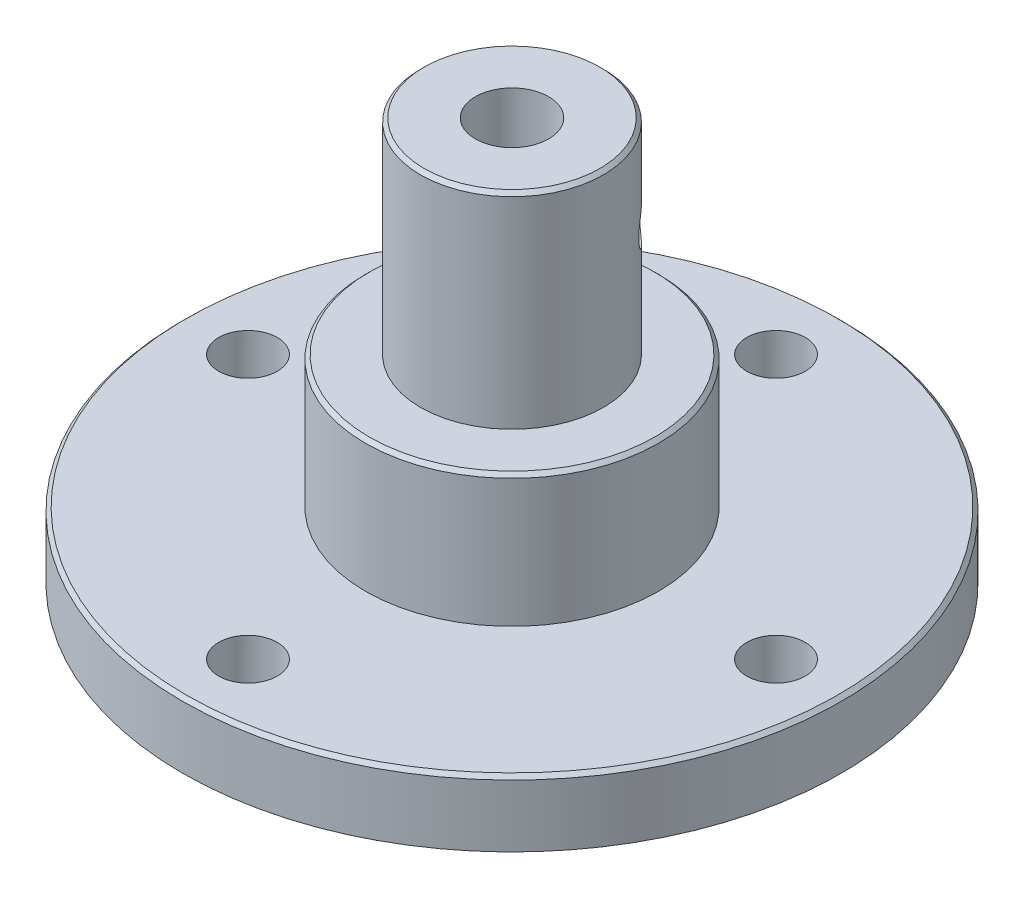
from build123d import *

# Parameters (mm, degrees)
SKETCH1_R           = 45
BOSS_EXTRUDE1_DEPTH = 9
SKETCH3_R           = 20
BOSS_EXTRUDE2_DEPTH = 18
SKETCH4_R           = 12.5
BOSS_EXTRUDE3_DEPTH = 28
SKETCH5_R           = 28.5
BOSS_EXTRUDE4_DEPTH = 2
SKETCH6_R           = 5
CUT_EXTRUDE1_DEPTH  = 40
CUT_EXTRUDE2_REACH  = 57
SKETCH8_R           = 4
CUT_EXTRUDE3_REACH  = 78.14
SKETCH9_R           = 2.5
CHAMFER1_SIZE       = 0.5


with BuildPart() as part:
    # Sketch1 → Boss-Extrude1 (new body)
    with BuildSketch(Plane(origin=(0, 0, 0), x_dir=(1, 0, 0), z_dir=(0, 1, 0))):
        Circle(SKETCH1_R)
    extrude(amount=BOSS_EXTRUDE1_DEPTH)

    # Sketch3 → Boss-Extrude2 (add)
    with BuildSketch(Plane(origin=(0, 9, 0), x_dir=(1, 0, 0), z_dir=(0, 1, 0))):
        Circle(SKETCH3_R)
    extrude(amount=BOSS_EXTRUDE2_DEPTH)

    # Sketch4 → Boss-Extrude3 (add)
    with BuildSketch(Plane(origin=(0, 27, 0), x_dir=(1, 0, 0), z_dir=(0, 1, 0))):
        Circle(SKETCH4_R)
    extrude(amount=BOSS_EXTRUDE3_DEPTH)

    # Sketch5 → Boss-Extrude4 (add)
    with BuildSketch(Plane.XZ):
        Circle(SKETCH5_R)
    extrude(amount=BOSS_EXTRUDE4_DEPTH)

    # Sketch6 → Cut-Extrude1 (cut)
    with BuildSketch(Plane(origin=(0, 55, 0), x_dir=(1, 0, 0), z_dir=(0, 1, 0))):
        Circle(SKETCH6_R)
    extrude(amount=-CUT_EXTRUDE1_DEPTH, mode=Mode.SUBTRACT)

    # Sketch7 → Cut-Revolve1 (revolve, cut)
    with BuildSketch(Plane(origin=(0, 0, 0), x_dir=(0, 0, -1), z_dir=(1, 0, 0))):
        with BuildLine():
            add(Edge.make_bspline(
                [(-15, 4), (-8.560208032, 11.204773426), (0, 13)],
                knots=[0, 0, 0, 1, 1, 1], degree=2))
            Line((0, 13), (0, -2))
            Line((0, -2), (-15, -2))
            Line((-15, -2), (-15, 4))
        make_face()
    revolve(axis=Axis((0, -2, 0), (0, 1, 0)), mode=Mode.SUBTRACT)

    # Sketch8 → Cut-Extrude2 (cut, up to next)
    with BuildSketch(Plane.XZ, mode=Mode.PRIVATE) as cut_extrude2_sk1:
        with Locations((0, 36.05)):
            Circle(SKETCH8_R)
    cut_extrude2_tool1 = extrude(cut_extrude2_sk1.sketch, amount=-CUT_EXTRUDE2_REACH, mode=Mode.PRIVATE) & part.part
    add(cut_extrude2_tool1.solids().sort_by_distance((0, 0, 36.05))[0], mode=Mode.SUBTRACT)
    # Sketch8 → Cut-Extrude2 (cut, up to next)
    with BuildSketch(Plane.XZ, mode=Mode.PRIVATE) as cut_extrude2_sk2:
        with Locations((-36.05, 0)):
            Circle(SKETCH8_R)
    cut_extrude2_tool2 = extrude(cut_extrude2_sk2.sketch, amount=-CUT_EXTRUDE2_REACH, mode=Mode.PRIVATE) & part.part
    add(cut_extrude2_tool2.solids().sort_by_distance((-36.05, 0, 0))[0], mode=Mode.SUBTRACT)
    # Sketch8 → Cut-Extrude2 (cut, up to next)
    with BuildSketch(Plane.XZ, mode=Mode.PRIVATE) as cut_extrude2_sk3:
        with Locations((0, -36.05)):
            Circle(SKETCH8_R)
    cut_extrude2_tool3 = extrude(cut_extrude2_sk3.sketch, amount=-CUT_EXTRUDE2_REACH, mode=Mode.PRIVATE) & part.part
    add(cut_extrude2_tool3.solids().sort_by_distance((0, 0, -36.05))[0], mode=Mode.SUBTRACT)
    # Sketch8 → Cut-Extrude2 (cut, up to next)
    with BuildSketch(Plane.XZ, mode=Mode.PRIVATE) as cut_extrude2_sk4:
        with Locations((36.05, 0)):
            Circle(SKETCH8_R)
    cut_extrude2_tool4 = extrude(cut_extrude2_sk4.sketch, amount=-CUT_EXTRUDE2_REACH, mode=Mode.PRIVATE) & part.part
    add(cut_extrude2_tool4.solids().sort_by_distance((36.05, 0, 0))[0], mode=Mode.SUBTRACT)

    # Sketch9 → Cut-Extrude3 (cut, up to next)
    with BuildSketch(Plane(origin=(8.838834765, 0, -8.838834765), x_dir=(0, -1, 0), z_dir=(-0.707106781, 0, 0.707106781)), mode=Mode.PRIVATE) as cut_extrude3_sk1:
        with Locations((-42.5, 0)):
            Circle(SKETCH9_R)
    cut_extrude3_tool1 = extrude(cut_extrude3_sk1.sketch, amount=CUT_EXTRUDE3_REACH, mode=Mode.PRIVATE) & part.part
    add(cut_extrude3_tool1.solids().sort_by_distance((8.838835, 42.5, -8.838835))[0], mode=Mode.SUBTRACT)

    # Chamfer1
    chamfer1_edges = [part.edges().sort_by_distance(p)[0] for p in [
        (-12.5, 55, 0),
        (-45, 9, 0),
        (-20, 27, 0),
    ]]
    chamfer(chamfer1_edges, length=CHAMFER1_SIZE)


solid = part.part
